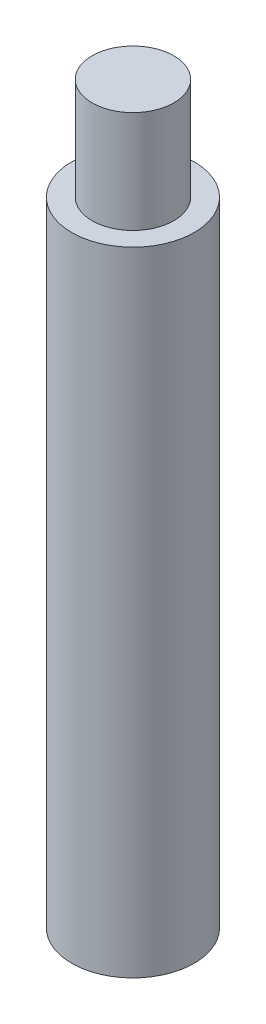
from build123d import *


with BuildPart() as part:
    # Sketch1 → Revolve1 (revolve)
    with BuildSketch(Plane.XY):
        Polygon((0, 0), (1.5, 0), (1.5, 15.5), (1, 15.5), (1, 18), (0, 18), align=None)
    revolve(axis=Axis((0, 18, 0), (0, -1, 0)))


solid = part.part
